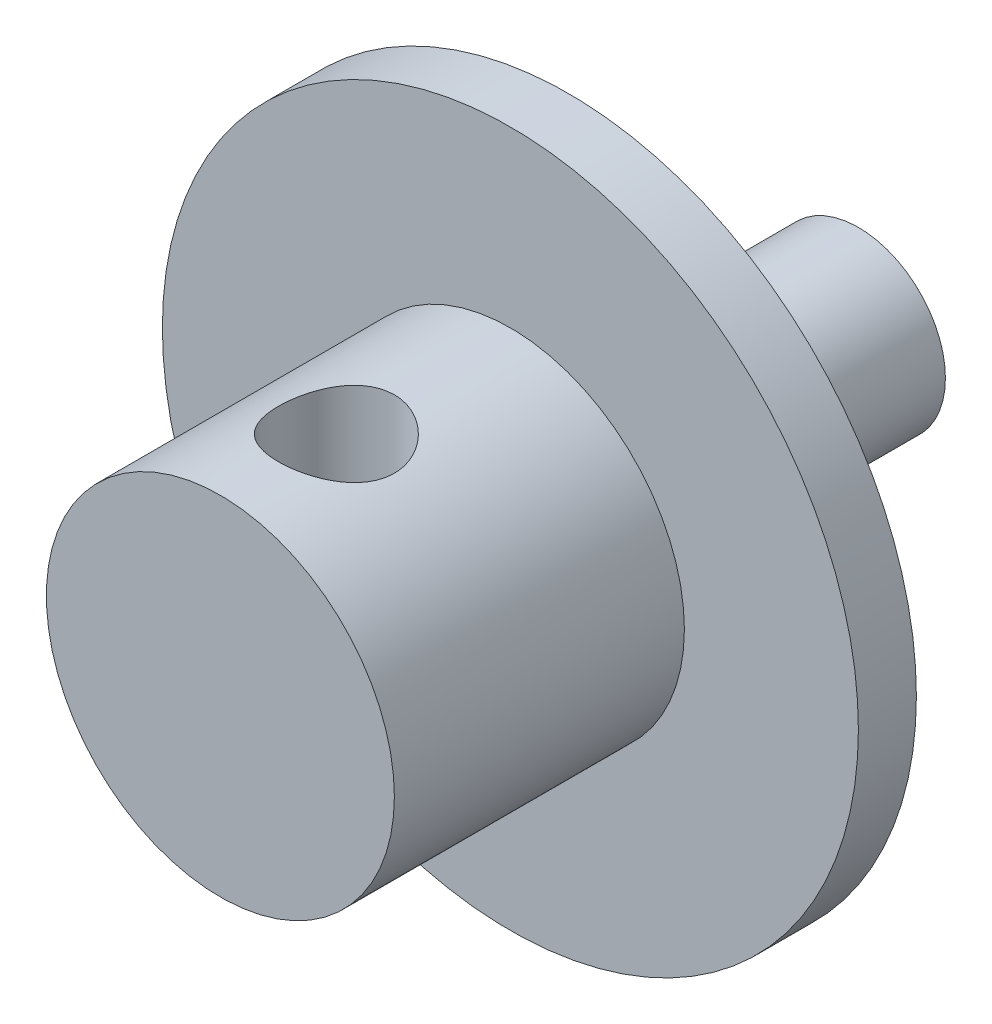
from build123d import *

# Parameters (mm, degrees)
ESQUISSE1_R                  = 1.5
BOSS_EXTRU_1_DEPTH           = 5
ESQUISSE2_R                  = 6
BOSS_EXTRU_2_DEPTH           = 1
ESQUISSE3_R                  = 3
BOSS_EXTRU_3_DEPTH           = 5
ENL_V_MAT_EXTRU_1_DEPTH      = 5
ENL_V_MAT_EXTRU_1_DEPTH_BACK = 5
ESQUISSE4_R                  = 1


with BuildPart() as part:
    # Esquisse1 → Boss.-Extru.1 (new body)
    with BuildSketch(Plane.XY):
        Circle(ESQUISSE1_R)
    extrude(amount=BOSS_EXTRU_1_DEPTH)

    # Esquisse2 → Boss.-Extru.2 (add)
    with BuildSketch(Plane.XY.offset(5)):
        Circle(ESQUISSE2_R)
    extrude(amount=BOSS_EXTRU_2_DEPTH)

    # Esquisse3 → Boss.-Extru.3 (add)
    with BuildSketch(Plane.XY.offset(6)):
        Circle(ESQUISSE3_R)
    extrude(amount=BOSS_EXTRU_3_DEPTH)

    # Esquisse4 → Enlèv. mat.-Extru.1 (cut, two sides: drawn at the far end of the back side and taken through both)
    with BuildSketch(Plane(origin=(0, 0, 0), x_dir=(1, 0, 0), z_dir=(0, 1, 0)).offset(-ENL_V_MAT_EXTRU_1_DEPTH_BACK)):
        with Locations((0, -9)):
            Circle(ESQUISSE4_R)
    extrude(amount=ENL_V_MAT_EXTRU_1_DEPTH + ENL_V_MAT_EXTRU_1_DEPTH_BACK, mode=Mode.SUBTRACT)


solid = part.part
